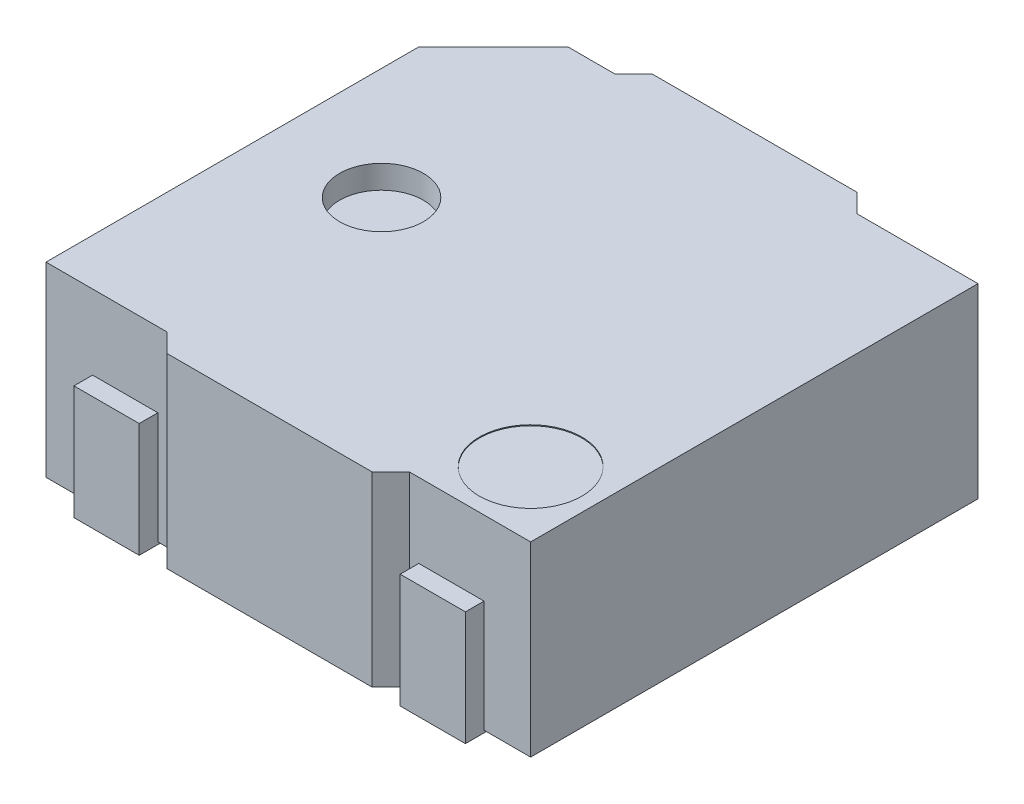
from build123d import *

# Parameters (mm, degrees)
SKETCH_1_W           = 5.2
SKETCH_1_H           = 5.2
EXTRUDE_1_DEPTH      = 2
CUT_EXTRUDE_1_DEPTH  = 2
SKETCH_4_R           = 0.45
CUT_EXTRUDE_2_DEPTH  = 0.25
SKETCH_7_R           = 0.8
CUT_EXTRUDE_4_DEPTH  = 0.2
CUT_EXTRUDE_5_DEPTH  = 3
SKETCH_8_W           = 0.7
SKETCH_8_H           = 0.9
EXTRUDE_2_DEPTH      = 0.025
EXTRUDE_2_DEPTH_BACK = 1.2
SKETCH_5_R           = 0.55
CUT_EXTRUDE_3_DEPTH  = 0.01


with BuildPart() as part:
    # 草图1 → 凸台-拉伸1 (new body)
    with BuildSketch(Plane(origin=(0, 0.025, 0), x_dir=(1, 0, 0), z_dir=(0, 1, 0))):
        Rectangle(SKETCH_1_W, SKETCH_1_H)
    extrude(amount=EXTRUDE_1_DEPTH)

    # 草图3 → 切除-拉伸1 (cut)
    with BuildSketch(Plane(origin=(0, 2.025, 0), x_dir=(1, 0, 0), z_dir=(0, 1, 0))):
        Polygon((-2.6, 1.6), (-1.6, 2.6), (-2.6, 2.6), align=None)
    extrude(amount=-CUT_EXTRUDE_1_DEPTH, mode=Mode.SUBTRACT)

    # 草图4 → 切除-拉伸2 (cut)
    with BuildSketch(Plane(origin=(0, 2.025, 0), x_dir=(1, 0, 0), z_dir=(0, 1, 0))):
        with Locations((-1.4, 0)):
            Circle(SKETCH_4_R)
    extrude(amount=-CUT_EXTRUDE_2_DEPTH, mode=Mode.SUBTRACT)

    # 草图7 → 切除-拉伸4 (cut)
    with BuildSketch(Plane(origin=(0, 1.775, 0), x_dir=(1, 0, 0), z_dir=(0, 1, 0))):
        with Locations((-1.4, 0)):
            Circle(SKETCH_7_R)
    extrude(amount=-CUT_EXTRUDE_4_DEPTH, mode=Mode.SUBTRACT)

    # 草图9 → 切除-拉伸5 (cut, through all)
    with BuildSketch(Plane(origin=(0, 2.025, 0), x_dir=(1, 0, 0), z_dir=(0, 1, 0))):
        Polygon((-2.6, -2.4), (-1.3, -2.4), (-1.1, -2.6), (1.1, -2.6), (1.3, -2.4), (2.6, -2.4), (2.6, -3.137806102), (-2.6, -3.137806102), align=None)
        Polygon((2.6, 3.137806102), (-2.6, 3.137806102), (-2.6, 2.4), (-1.3, 2.4), (-1.1, 2.6), (1.1, 2.6), (1.3, 2.4), (2.6, 2.4), align=None)
    extrude(amount=-CUT_EXTRUDE_5_DEPTH, mode=Mode.SUBTRACT)

    # 草图8 → 凸台-拉伸2 (add, two sides)
    with BuildSketch(Plane.XZ.offset(-0.025)) as extrude_2_sk:
        with Locations((1.75, 2.15)):
            Rectangle(SKETCH_8_W, SKETCH_8_H)
        with Locations((-1.75, 2.15)):
            Rectangle(SKETCH_8_W, SKETCH_8_H)
        with Locations((1.75, -2.15)):
            Rectangle(SKETCH_8_W, SKETCH_8_H)
    extrude(amount=EXTRUDE_2_DEPTH)
    extrude(extrude_2_sk.sketch, amount=-EXTRUDE_2_DEPTH_BACK)

    # 草图5 → 切除-拉伸3 (cut)
    with BuildSketch(Plane(origin=(0, 2.025, 0), x_dir=(1, 0, 0), z_dir=(0, 1, 0))):
        with Locations((1.9, -1.7)):
            Circle(SKETCH_5_R)
    extrude(amount=-CUT_EXTRUDE_3_DEPTH, mode=Mode.SUBTRACT)


solid = part.part
